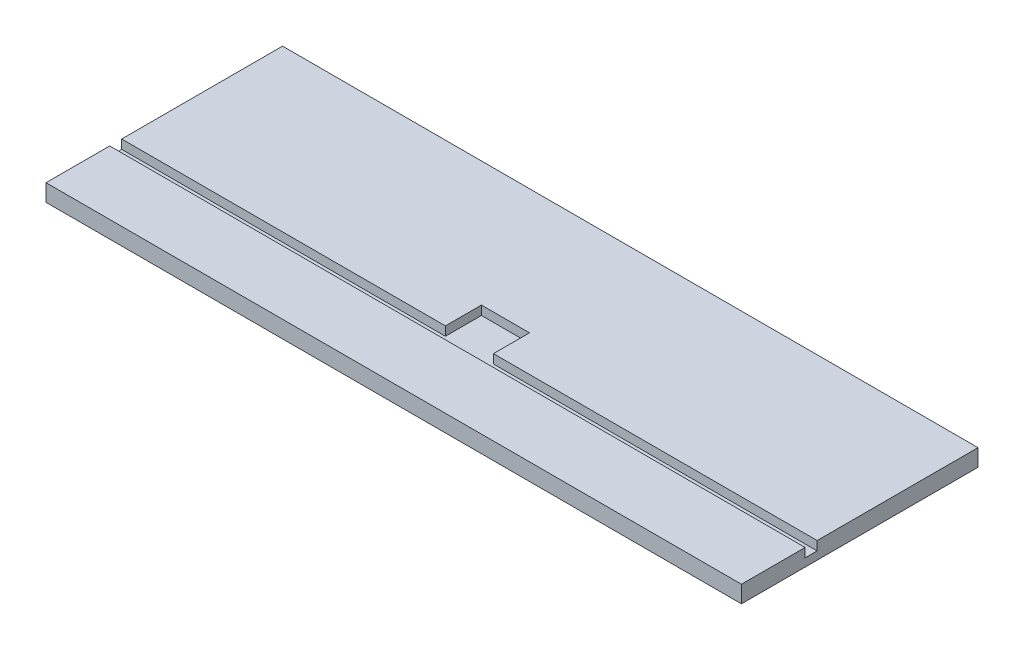
from build123d import *

# Parameters (mm, degrees)
SKETCH1_W           = 735
SKETCH1_H           = 250
BOSS_EXTRUDE1_DEPTH = 18
CUT_EXTRUDE1_DEPTH  = 9.525


with BuildPart() as part:
    # Sketch1 → Boss-Extrude1 (new body)
    with BuildSketch(Plane(origin=(0, 0, 0), x_dir=(1, 0, 0), z_dir=(0, 1, 0))):
        Rectangle(SKETCH1_W, SKETCH1_H)
    extrude(amount=BOSS_EXTRUDE1_DEPTH)

    # Sketch4 → Cut-Extrude1 (cut)
    with BuildSketch(Plane(origin=(0, 18, 0), x_dir=(1, 0, 0), z_dir=(0, 1, 0))):
        Polygon((-390.644484973, -45), (-25.4, -45), (-25.4, -6.9), (25.4, -6.9), (25.4, -45), (418.930169805, -45), (418.930169805, -57.7), (-390.644484973, -57.7), align=None)
    extrude(amount=-CUT_EXTRUDE1_DEPTH, mode=Mode.SUBTRACT)


solid = part.part
